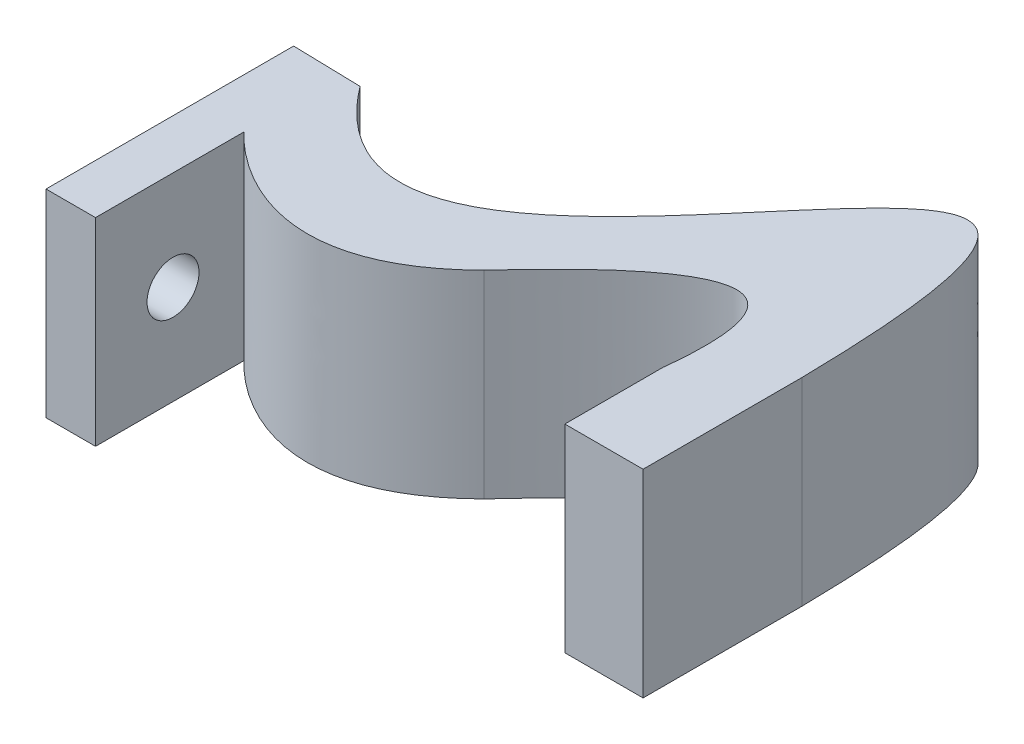
from build123d import *

# Parameters (mm, degrees)
BOSS_EXTRUDE3_DEPTH = 20
SKETCH3_R           = 2.625
CUT_EXTRUDE1_DEPTH  = 6.0000001
SKETCH4_W           = 8.823264565
SKETCH4_H           = 5
BOSS_EXTRUDE4_DEPTH = 0.5


with BuildPart() as part:
    # Sketch1 → Boss-Extrude3 (new body)
    with BuildSketch(Plane(origin=(0, 0, 0), x_dir=(1, 0, 0), z_dir=(0, 1, 0))):
        with BuildLine():
            Line((-24.199448649, 0), (-24.199448649, -4.824773701))
            Line((-24.199448649, -4.824773701), (-24.199448649, -15.004197918))
            Line((-24.199448649, -15.004197918), (-29.199448649, -15.004197918))
            Line((-29.199448649, -15.004197918), (-29.199448649, -4.824773701))
            Line((-29.199448649, -4.824773701), (-29.199448649, 9.995802082))
            Line((-29.199448649, 9.995802082), (-22.322379413, 9.822250815))
            add(Edge.make_bspline(
                [(-22.322379413, 9.822250815), (0.232629534, -19.940907612), (24.467567917, 67.681570283), (25.436252045, 6.659493601)],
                knots=[0, 0, 0, 0, 1, 1, 1, 1], degree=3))
            Line((25.436252045, 6.659493601), (25.436252045, -9.362628557))
            Line((25.436252045, -9.362628557), (17.536308623, -9.362628557))
            Line((17.536308623, -9.362628557), (17.536308623, 0.546329))
            add(Edge.make_bspline(
                [(0, 0), (19.89900847, 21.841866163), (17.536308623, 0.546329)],
                knots=[0, 0, 0, 1, 1, 1], degree=2))
            add(Edge.make_bspline(
                [(-24.199448649, 0), (-24.197798481, -0.001931794), (-13.033999021, -12.890058665), (0, 0)],
                knots=[0, 0, 0, 0, 1, 1, 1, 1], degree=3))
        make_face()
    extrude(amount=BOSS_EXTRUDE3_DEPTH)

    # Sketch3 → Cut-Extrude1 (cut, through all)
    with BuildSketch(Plane(origin=(-24.199448649, 0, 0), x_dir=(0, 0, -1), z_dir=(1, 0, 0))):
        with Locations((-7.181936729, 10)):
            Circle(SKETCH3_R)
    extrude(amount=-CUT_EXTRUDE1_DEPTH, mode=Mode.SUBTRACT)

    # Sketch4 → Boss-Extrude4 (add)
    with BuildSketch(Plane.ZY.offset(29.199448649)):
        with Locations((-2.086858582, 10)):
            Rectangle(SKETCH4_W, SKETCH4_H)
    extrude(amount=BOSS_EXTRUDE4_DEPTH)


solid = part.part
